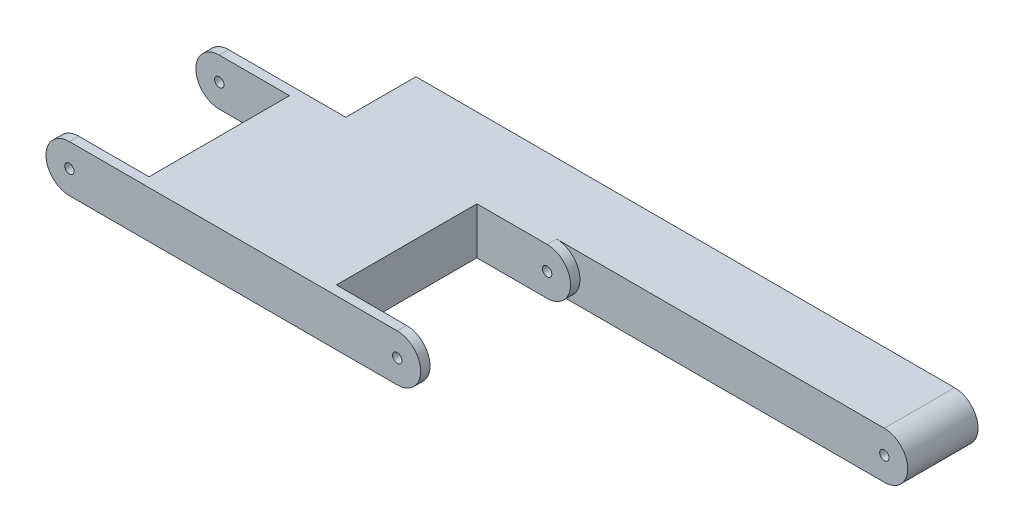
from build123d import *

# Parameters (mm, degrees)
EXTRUDE_1_DEPTH          = 34
SKETCH_2_R               = 1
CUT_EXTRUDE_4_DEPTH      = 35
CUT_EXTRUDE_4_DEPTH_BACK = 30
SKETCH_3_W               = 20
SKETCH_3_H               = 30
CUT_EXTRUDE_5_DEPTH      = 30
CUT_EXTRUDE_5_DEPTH_BACK = 30
EXTRUDE_4_DEPTH          = 15
SKETCH_5_R               = 1
CUT_EXTRUDE_7_DEPTH      = 16
SKETCH_6_W               = 15
SKETCH_6_H               = 10
EXTRUDE_5_DEPTH          = 10


with BuildPart() as part:
    # 草圖1 → 填料-伸長1 (new body)
    with BuildSketch(Plane.XY):
        with BuildLine():
            Line((-35, 5), (35, 5))
            ThreePointArc((35, 5), (40, 0), (35, -5))
            Line((35, -5), (-35, -5))
            ThreePointArc((-35, -5), (-40, 0), (-35, 5))
        make_face()
    extrude(amount=EXTRUDE_1_DEPTH)

    # 草圖2 → 除料-伸長4 (cut, two sides)
    with BuildSketch(Plane.XY) as cut_extrude_4_sk:
        with Locations((-35, 0)):
            Circle(SKETCH_2_R)
        with Locations((35, 0)):
            Circle(SKETCH_2_R)
    extrude(amount=CUT_EXTRUDE_4_DEPTH, mode=Mode.SUBTRACT)
    extrude(cut_extrude_4_sk.sketch, amount=-CUT_EXTRUDE_4_DEPTH_BACK, mode=Mode.SUBTRACT)

    # 草圖3 → 除料-伸長5 (cut, two sides)
    with BuildSketch(Plane(origin=(0, 0, 0), x_dir=(1, 0, 0), z_dir=(0, 1, 0))) as cut_extrude_5_sk:
        with Locations((-30, -17)):
            Rectangle(SKETCH_3_W, SKETCH_3_H)
        with Locations((30, -17)):
            Rectangle(SKETCH_3_W, SKETCH_3_H)
    extrude(amount=CUT_EXTRUDE_5_DEPTH, mode=Mode.SUBTRACT)
    extrude(cut_extrude_5_sk.sketch, amount=-CUT_EXTRUDE_5_DEPTH_BACK, mode=Mode.SUBTRACT)

    # 草圖4 → 填料-伸長4 (add)
    with BuildSketch(Plane.XY):
        with BuildLine():
            Line((0, 5), (105, 5))
            ThreePointArc((105, 5), (110, 0), (105, -5))
            Line((105, -5), (0, -5))
            Line((0, -5), (0, 5))
        make_face()
    extrude(amount=-EXTRUDE_4_DEPTH)

    # 草圖5 → 除料-伸長7 (cut, through all)
    with BuildSketch(Plane.XY):
        with Locations((35, 0)):
            Circle(SKETCH_5_R)
        with Locations((105, 0)):
            Circle(SKETCH_5_R)
    extrude(amount=-CUT_EXTRUDE_7_DEPTH, mode=Mode.SUBTRACT)

    # 草圖6 → 填料-伸長5 (add)
    with BuildSketch(Plane(origin=(0, 0, 0), x_dir=(0, 0, -1), z_dir=(1, 0, 0))):
        with Locations((7.5, 0)):
            Rectangle(SKETCH_6_W, SKETCH_6_H)
    extrude(amount=-EXTRUDE_5_DEPTH)


solid = part.part
